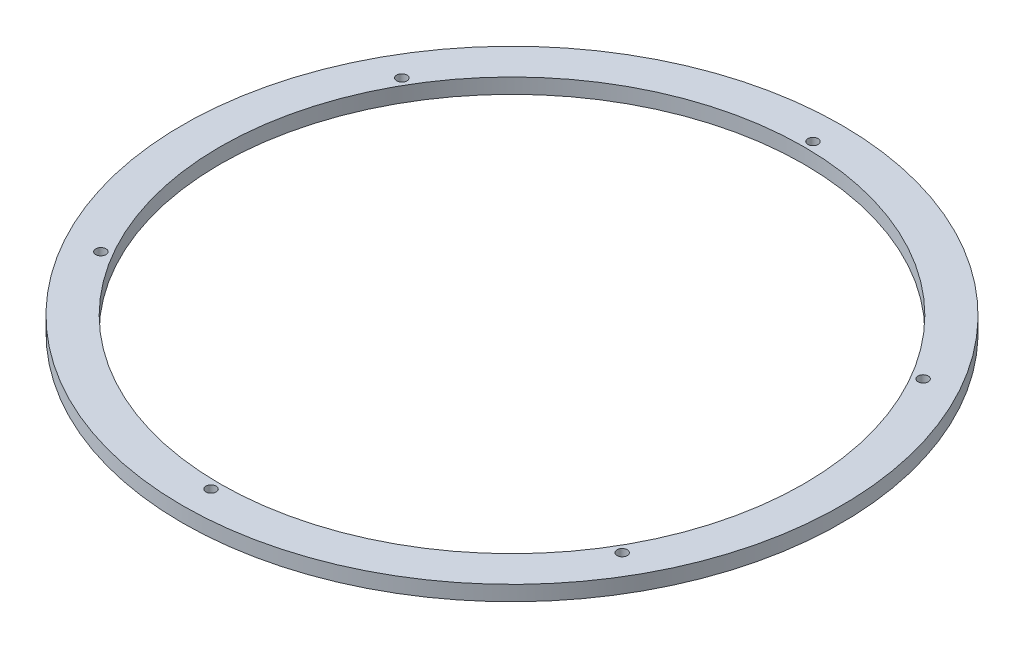
from build123d import *

# Parameters (mm, degrees)
SKETCH1_R                     = 111.252
SKETCH1_R_2                   = 98.552
BOSS_EXTRUDE1_DEPTH           = 5.08
TAP_DRILL_FOR_8_32_TAP1_D     = 3.4544
TAP_DRILL_FOR_8_32_TAP1_DEPTH = 25.4
TAP_DRILL_FOR_8_32_TAP1_TIP   = 1.037806461


with BuildPart() as part:
    # Sketch1 → Boss-Extrude1 (new body)
    with BuildSketch(Plane(origin=(0, 0, 0), x_dir=(1, 0, 0), z_dir=(0, 1, 0))):
        Circle(SKETCH1_R)
        Circle(SKETCH1_R_2, mode=Mode.SUBTRACT)
    extrude(amount=BOSS_EXTRUDE1_DEPTH)

    # Tap Drill for #8-32 Tap1
    with Locations(Plane(origin=(0, 5.08, 0), x_dir=(1, 0, 0), z_dir=(0, 1, 0))):
        with Locations((-87.988181024, 50.8), (0, 101.6), (87.988181024, 50.8), (87.988181024, -50.8), (0, -101.6), (-87.988181024, -50.8)):
            Hole(TAP_DRILL_FOR_8_32_TAP1_D / 2, depth=TAP_DRILL_FOR_8_32_TAP1_DEPTH)
            with Locations((0, 0, -(TAP_DRILL_FOR_8_32_TAP1_DEPTH + TAP_DRILL_FOR_8_32_TAP1_TIP / 2))):  # 118° drill point
                Cone(0, TAP_DRILL_FOR_8_32_TAP1_D / 2, TAP_DRILL_FOR_8_32_TAP1_TIP, mode=Mode.SUBTRACT)


solid = part.part
